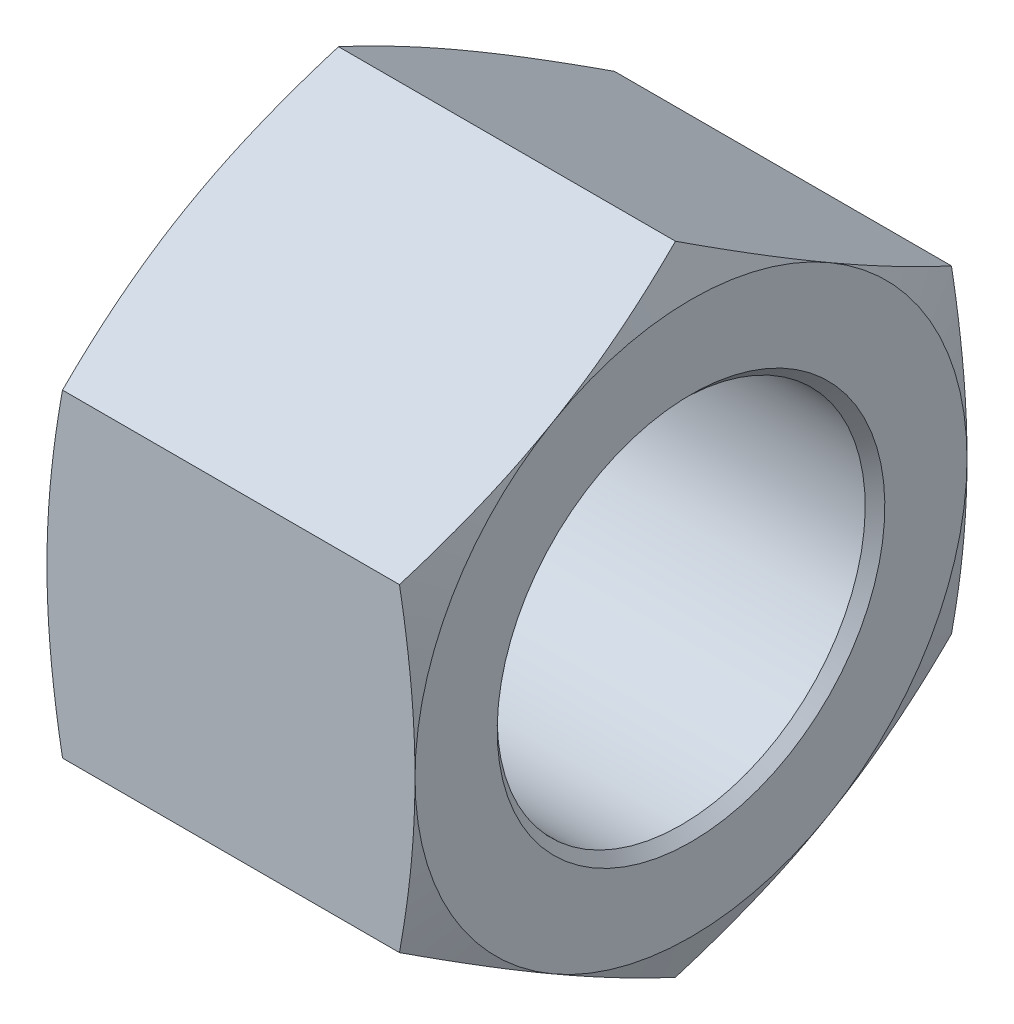
from build123d import *

# Parameters (mm, degrees)
SKETCH1_R           = 4.7625
BOSS_EXTRUDE1_DEPTH = 9.525


with BuildPart() as part:
    # Sketch1 → Boss-Extrude1 (new body)
    with BuildSketch(Plane(origin=(0, 0, 0), x_dir=(0, 0, -1), z_dir=(1, 0, 0))):
        Polygon((0, 8.248891971), (-7.14375, 4.124445986), (-7.14375, -4.124445986), (0, -8.248891971), (7.14375, -4.124445986), (7.14375, 4.124445986), align=None)
        Circle(SKETCH1_R, mode=Mode.SUBTRACT)
    extrude(amount=BOSS_EXTRUDE1_DEPTH)

    # Sketch2 → Cut-Revolve1 (revolve, cut)
    with BuildSketch(Plane.XY):
        Polygon((0, 7.14375), (0.402238782, 8.248891971), (0, 8.248891971), align=None)
        Polygon((0, 4.7625), (0.254, 4.7625), (0, 5.0165), align=None)
        Polygon((9.525, 5.0165), (9.525, 4.7625), (9.271, 4.7625), align=None)
        Polygon((9.525, 8.248891971), (9.525, 7.14375), (9.122761218, 8.248891971), align=None)
    revolve(axis=Axis((0, 0, 0), (1, 0, 0)), mode=Mode.SUBTRACT)


solid = part.part
